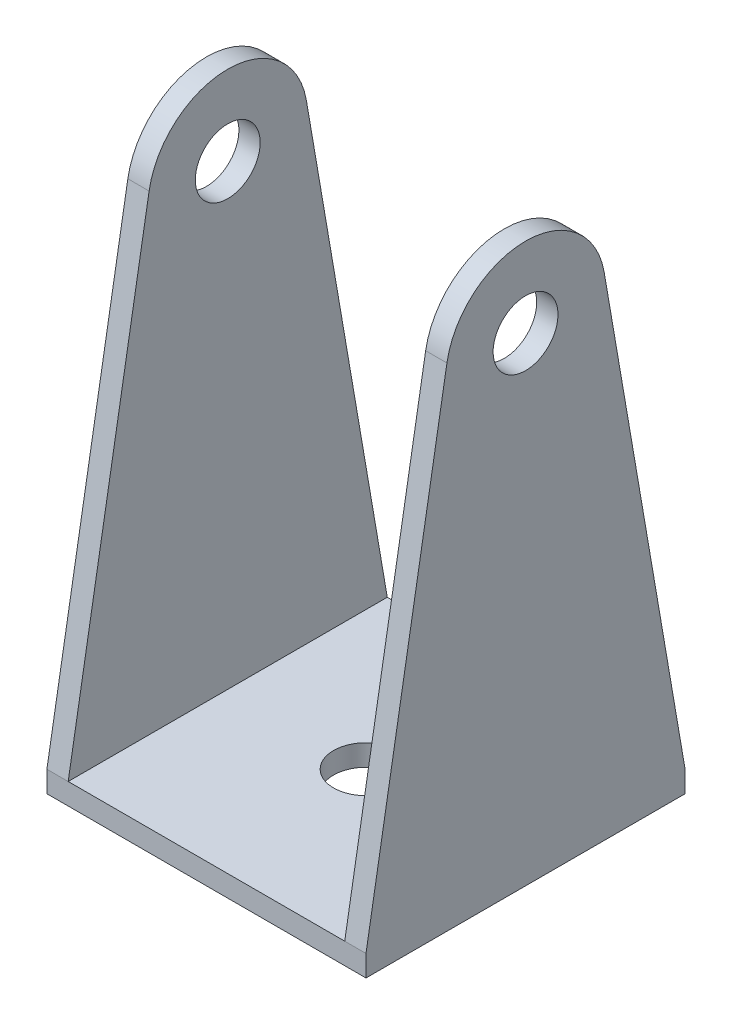
from build123d import *

# Parameters (mm, degrees)
EXTRUDE_1_DEPTH     = 30
SKETCH_2_R          = 3.05
CUT_EXTRUDE_1_DEPTH = 30
SKETCH_3_R          = 3.05
CUT_EXTRUDE_2_DEPTH = 30
CUT_EXTRUDE_3_DEPTH = 54


with BuildPart() as part:
    # 草图1 → 凸台-拉伸1 (new body)
    with BuildSketch(Plane.XY):
        Polygon((-13, -20.797836643), (-13, -73.797836643), (13, -73.797836643), (13, -20.797836643), (15, -20.797836643), (15, -75.797836643), (-15, -75.797836643), (-15, -20.797836643), align=None)
    extrude(amount=EXTRUDE_1_DEPTH)

    # 草图2 → 切除-拉伸1 (cut)
    with BuildSketch(Plane.XZ.offset(75.797836643)):
        with Locations((0, 15)):
            Circle(SKETCH_2_R)
    extrude(amount=-CUT_EXTRUDE_1_DEPTH, mode=Mode.SUBTRACT)

    # 草图3 → 切除-拉伸2 (cut)
    with BuildSketch(Plane(origin=(15, 0, 0), x_dir=(0, 0, -1), z_dir=(1, 0, 0))):
        with Locations((-15, -30.797836643)):
            Circle(SKETCH_3_R)
    extrude(amount=-CUT_EXTRUDE_2_DEPTH, mode=Mode.SUBTRACT)

    # 草图4 → 切除-拉伸3 (cut)
    with BuildSketch(Plane.ZY.offset(15)):
        with BuildLine():
            Line((0, -73.797836643), (7.608366664, -29.527499433))
            ThreePointArc((7.608366664, -29.527499433), (15, -23.297836643), (22.391633336, -29.527499433))
            Line((22.391633336, -29.527499433), (30, -73.797836643))
            Line((30, -73.797836643), (30, -20.797836643))
            Line((30, -20.797836643), (0, -20.797836643))
            Line((0, -20.797836643), (0, -73.797836643))
        make_face()
    extrude(amount=-CUT_EXTRUDE_3_DEPTH, mode=Mode.SUBTRACT)


solid = part.part
